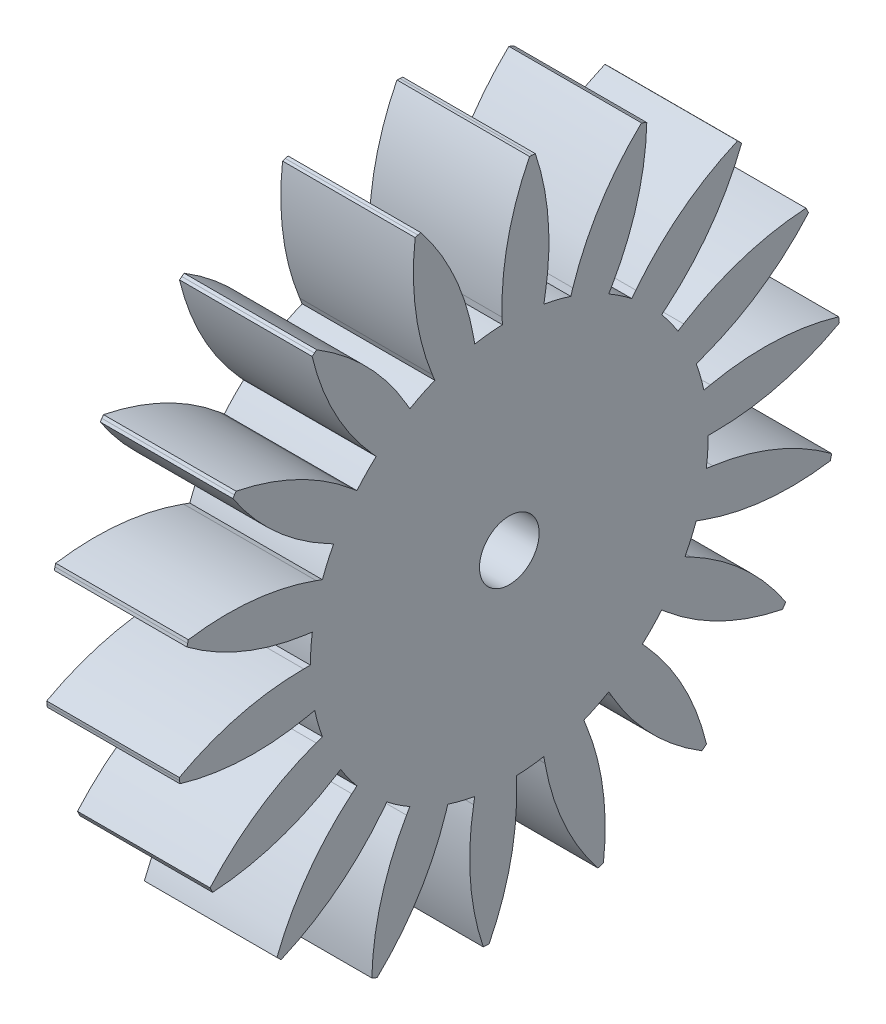
from build123d import *

# Parameters (mm, degrees)
SKETCH1_R           = 15
SKETCH1_R_2         = 2.25
BOSS_EXTRUDE2_DEPTH = 10


with BuildPart() as part:
    # Sketch1 → Boss-Extrude2 (new body)
    with BuildSketch(Plane(origin=(0, 0, 0), x_dir=(0, 0, -1), z_dir=(1, 0, 0))):
        with BuildLine():
            ThreePointArc((12.720721442, 7.948788963), (13.481910694, 6.575567202), (14.095389312, 5.13030215))
            Line((14.095389312, 5.13030215), (14.565235622, 5.301312222))
            ThreePointArc((14.565235622, 5.301312222), (18.908034497, 7.529506054), (22.564632109, 10.76277742))
            Line((22.564632109, 10.76277742), (22.469851157, 10.95927867))
            Line((22.469851157, 10.95927867), (22.37335904, 11.154945328))
            ThreePointArc((22.37335904, 11.154945328), (17.574280154, 10.264107707), (13.14474549, 8.213748596))
            Line((13.14474549, 8.213748596), (12.720721442, 7.948788963))
        make_face()
        with BuildLine():
            ThreePointArc((9.23492213, 11.820161304), (10.419875557, 10.790097005), (11.490666647, 9.641814145))
            Line((11.490666647, 9.641814145), (11.873688868, 9.96320795))
            ThreePointArc((11.873688868, 9.96320795), (15.19249775, 13.542349946), (17.522731607, 17.831261229))
            Line((17.522731607, 17.831261229), (17.366459261, 17.983495008))
            Line((17.366459261, 17.983495008), (17.208864392, 18.134359275))
            ThreePointArc((17.208864392, 18.134359275), (13.003889787, 15.655864088), (9.542752868, 12.214166681))
            Line((9.542752868, 12.214166681), (9.23492213, 11.820161304))
        make_face()
        with BuildLine():
            ThreePointArc((4.635254916, 14.265847744), (6.101049646, 13.703181865), (7.5, 12.990381057))
            Line((7.5, 12.990381057), (7.75, 13.423393759))
            ThreePointArc((7.75, 13.423393759), (9.644521558, 17.92178657), (10.367331066, 22.749031772))
            Line((10.367331066, 22.749031772), (10.168416077, 22.838636441))
            Line((10.168416077, 22.838636441), (9.968726723, 22.92650186))
            ThreePointArc((9.968726723, 22.92650186), (6.865038395, 19.159292205), (4.789763413, 14.741376003))
            Line((4.789763413, 14.741376003), (4.635254916, 14.265847744))
        make_face()
        with BuildLine():
            ThreePointArc((-0.523492451, 14.990862405), (1.046347106, 14.963460754), (2.604722665, 14.772116295))
            Line((2.604722665, 14.772116295), (2.691546754, 15.264520172))
            ThreePointArc((2.691546754, 15.264520172), (2.933273727, 20.139591237), (1.961477393, 24.922933343))
            Line((1.961477393, 24.922933343), (1.743911844, 24.939101256))
            Line((1.743911844, 24.939101256), (1.526213488, 24.953369961))
            ThreePointArc((1.526213488, 24.953369961), (-0.101837945, 20.35182692), (-0.540942199, 15.490557819))
            Line((-0.540942199, 15.490557819), (-0.523492451, 14.990862405))
        make_face()
        with BuildLine():
            ThreePointArc((-5.619098901, 13.907757819), (-4.134560337, 14.418925439), (-2.604722665, 14.772116295))
            Line((-2.604722665, 14.772116295), (-2.691546754, 15.264520172))
            ThreePointArc((-2.691546754, 15.264520172), (-4.131770205, 19.928263972), (-6.680959402, 24.09076133))
            Line((-6.680959402, 24.09076133), (-6.890933895, 24.031542398))
            Line((-6.890933895, 24.031542398), (-7.100383618, 23.970493372))
            ThreePointArc((-7.100383618, 23.970493372), (-7.056431125, 19.089630948), (-5.806402198, 14.371349746))
            Line((-5.806402198, 14.371349746), (-5.619098901, 13.907757819))
        make_face()
        with BuildLine():
            ThreePointArc((-10.036959095, 11.147172382), (-8.816778784, 12.135254916), (-7.5, 12.990381057))
            Line((-7.5, 12.990381057), (-7.75, 13.423393759))
            ThreePointArc((-7.75, 13.423393759), (-10.698461672, 17.313293962), (-14.517573893, 20.352887959))
            Line((-14.517573893, 20.352887959), (-14.694631307, 20.225424859))
            Line((-14.694631307, 20.225424859), (-14.870569669, 20.096421515))
            ThreePointArc((-14.870569669, 20.096421515), (-13.15991457, 15.524943751), (-10.371524399, 11.518744795))
            Line((-10.371524399, 11.518744795), (-10.036959095, 11.147172382))
        make_face()
        with BuildLine():
            ThreePointArc((-13.244213893, 7.042073442), (-12.435563588, 8.387893552), (-11.490666647, 9.641814145))
            Line((-11.490666647, 9.641814145), (-11.873688868, 9.96320795))
            ThreePointArc((-11.873688868, 9.96320795), (-15.974760769, 12.610085183), (-20.603154716, 14.160155923))
            Line((-20.603154716, 14.160155923), (-20.725939314, 13.979822587))
            Line((-20.725939314, 13.979822587), (-20.847145552, 13.798424633))
            ThreePointArc((-20.847145552, 13.798424633), (-17.676118098, 10.087719213), (-13.685687689, 7.276809223))
            Line((-13.685687689, 7.276809223), (-13.244213893, 7.042073442))
        make_face()
        with BuildLine():
            ThreePointArc((-14.854021031, 2.087596514), (-14.554435894, 3.628828434), (-14.095389312, 5.13030215))
            Line((-14.095389312, 5.13030215), (-14.565235622, 5.301312222))
            ThreePointArc((-14.565235622, 5.301312222), (-19.324267955, 6.385914026), (-24.203691009, 6.259500101))
            Line((-24.203691009, 6.259500101), (-24.257393157, 6.04804739))
            Line((-24.257393157, 6.04804739), (-24.30924801, 5.836134096))
            ThreePointArc((-24.30924801, 5.836134096), (-20.060320912, 3.43376686), (-15.349155065, 2.157183065))
            Line((-15.349155065, 2.157183065), (-14.854021031, 2.087596514))
        make_face()
        with BuildLine():
            Line((-15.161287811, -3.222631208), (-14.672214011, -3.118675362))
            ThreePointArc((-14.672214011, -3.118675362), (-14.917828431, -1.567926949), (-15, 0))
            Line((-15, 0), (-15.5, 0))
            ThreePointArc((-15.5, 0), (-20.34298323, -0.608492609), (-24.884904959, -2.396143813))
            Line((-24.884904959, -2.396143813), (-24.863047384, -2.613211582))
            Line((-24.863047384, -2.613211582), (-24.839296392, -2.830080344))
            ThreePointArc((-24.839296392, -2.830080344), (-20.024952965, -3.634348454), (-15.161287811, -3.222631208))
        make_face()
        with BuildLine():
            Line((-13.14474549, -8.213748596), (-12.720721442, -7.948788963))
            ThreePointArc((-12.720721442, -7.948788963), (-13.481910694, -6.575567202), (-14.095389312, -5.13030215))
            Line((-14.095389312, -5.13030215), (-14.565235622, -5.301312222))
            ThreePointArc((-14.565235622, -5.301312222), (-18.908034497, -7.529506054), (-22.564632109, -10.76277742))
            Line((-22.564632109, -10.76277742), (-22.469851157, -10.95927867))
            Line((-22.469851157, -10.95927867), (-22.37335904, -11.154945328))
            ThreePointArc((-22.37335904, -11.154945328), (-17.574280154, -10.264107707), (-13.14474549, -8.213748596))
        make_face()
        with BuildLine():
            Line((-9.542752868, -12.214166681), (-9.23492213, -11.820161304))
            ThreePointArc((-9.23492213, -11.820161304), (-10.419875557, -10.790097005), (-11.490666647, -9.641814145))
            Line((-11.490666647, -9.641814145), (-11.873688868, -9.96320795))
            ThreePointArc((-11.873688868, -9.96320795), (-15.19249775, -13.542349946), (-17.522731607, -17.831261229))
            Line((-17.522731607, -17.831261229), (-17.366459261, -17.983495008))
            Line((-17.366459261, -17.983495008), (-17.208864392, -18.134359275))
            ThreePointArc((-17.208864392, -18.134359275), (-13.003889787, -15.655864088), (-9.542752868, -12.214166681))
        make_face()
        with BuildLine():
            Line((-4.789763413, -14.741376003), (-4.635254916, -14.265847744))
            ThreePointArc((-4.635254916, -14.265847744), (-6.101049646, -13.703181865), (-7.5, -12.990381057))
            Line((-7.5, -12.990381057), (-7.75, -13.423393759))
            ThreePointArc((-7.75, -13.423393759), (-9.644521558, -17.92178657), (-10.367331066, -22.749031772))
            Line((-10.367331066, -22.749031772), (-10.168416077, -22.838636441))
            Line((-10.168416077, -22.838636441), (-9.968726723, -22.92650186))
            ThreePointArc((-9.968726723, -22.92650186), (-6.865038395, -19.159292205), (-4.789763413, -14.741376003))
        make_face()
        with BuildLine():
            Line((0.540942199, -15.490557819), (0.523492451, -14.990862405))
            ThreePointArc((0.523492451, -14.990862405), (-1.046347106, -14.963460754), (-2.604722665, -14.772116295))
            Line((-2.604722665, -14.772116295), (-2.691546754, -15.264520172))
            ThreePointArc((-2.691546754, -15.264520172), (-2.933273727, -20.139591237), (-1.961477393, -24.922933343))
            Line((-1.961477393, -24.922933343), (-1.743911844, -24.939101256))
            Line((-1.743911844, -24.939101256), (-1.526213488, -24.953369961))
            ThreePointArc((-1.526213488, -24.953369961), (0.101837945, -20.35182692), (0.540942199, -15.490557819))
        make_face()
        with BuildLine():
            Line((5.806402198, -14.371349746), (5.619098901, -13.907757819))
            ThreePointArc((5.619098901, -13.907757819), (4.134560337, -14.418925439), (2.604722665, -14.772116295))
            Line((2.604722665, -14.772116295), (2.691546754, -15.264520172))
            ThreePointArc((2.691546754, -15.264520172), (4.131770205, -19.928263972), (6.680959402, -24.09076133))
            Line((6.680959402, -24.09076133), (6.890933895, -24.031542398))
            Line((6.890933895, -24.031542398), (7.100383618, -23.970493372))
            ThreePointArc((7.100383618, -23.970493372), (7.056431125, -19.089630948), (5.806402198, -14.371349746))
        make_face()
        with BuildLine():
            Line((10.371524399, -11.518744795), (10.036959095, -11.147172382))
            ThreePointArc((10.036959095, -11.147172382), (8.816778784, -12.135254916), (7.5, -12.990381057))
            Line((7.5, -12.990381057), (7.75, -13.423393759))
            ThreePointArc((7.75, -13.423393759), (10.698461672, -17.313293962), (14.517573893, -20.352887959))
            Line((14.517573893, -20.352887959), (14.694631307, -20.225424859))
            Line((14.694631307, -20.225424859), (14.870569669, -20.096421515))
            ThreePointArc((14.870569669, -20.096421515), (13.15991457, -15.524943751), (10.371524399, -11.518744795))
        make_face()
        with BuildLine():
            Line((13.685687689, -7.276809223), (13.244213893, -7.042073442))
            ThreePointArc((13.244213893, -7.042073442), (12.435563588, -8.387893552), (11.490666647, -9.641814145))
            Line((11.490666647, -9.641814145), (11.873688868, -9.96320795))
            ThreePointArc((11.873688868, -9.96320795), (15.974760769, -12.610085183), (20.603154716, -14.160155923))
            Line((20.603154716, -14.160155923), (20.725939314, -13.979822587))
            Line((20.725939314, -13.979822587), (20.847145552, -13.798424633))
            ThreePointArc((20.847145552, -13.798424633), (17.676118098, -10.087719213), (13.685687689, -7.276809223))
        make_face()
        with BuildLine():
            Line((15.349155065, -2.157183065), (14.854021031, -2.087596514))
            ThreePointArc((14.854021031, -2.087596514), (14.554435894, -3.628828434), (14.095389312, -5.13030215))
            Line((14.095389312, -5.13030215), (14.565235622, -5.301312222))
            ThreePointArc((14.565235622, -5.301312222), (19.324267955, -6.385914026), (24.203691009, -6.259500101))
            Line((24.203691009, -6.259500101), (24.257393157, -6.04804739))
            Line((24.257393157, -6.04804739), (24.30924801, -5.836134096))
            ThreePointArc((24.30924801, -5.836134096), (20.060320912, -3.43376686), (15.349155065, -2.157183065))
        make_face()
        with BuildLine():
            ThreePointArc((14.672214011, 3.118675362), (14.917828431, 1.567926949), (15, 0))
            Line((15, 0), (15.5, 0))
            ThreePointArc((15.5, 0), (20.34298323, 0.608492609), (24.884904959, 2.396143813))
            Line((24.884904959, 2.396143813), (24.863047384, 2.613211582))
            Line((24.863047384, 2.613211582), (24.839296392, 2.830080344))
            ThreePointArc((24.839296392, 2.830080344), (20.024952965, 3.634348454), (15.161287811, 3.222631208))
            Line((15.161287811, 3.222631208), (14.672214011, 3.118675362))
        make_face()
        Circle(SKETCH1_R)
        Circle(SKETCH1_R_2, mode=Mode.SUBTRACT)
    extrude(amount=BOSS_EXTRUDE2_DEPTH)


solid = part.part
